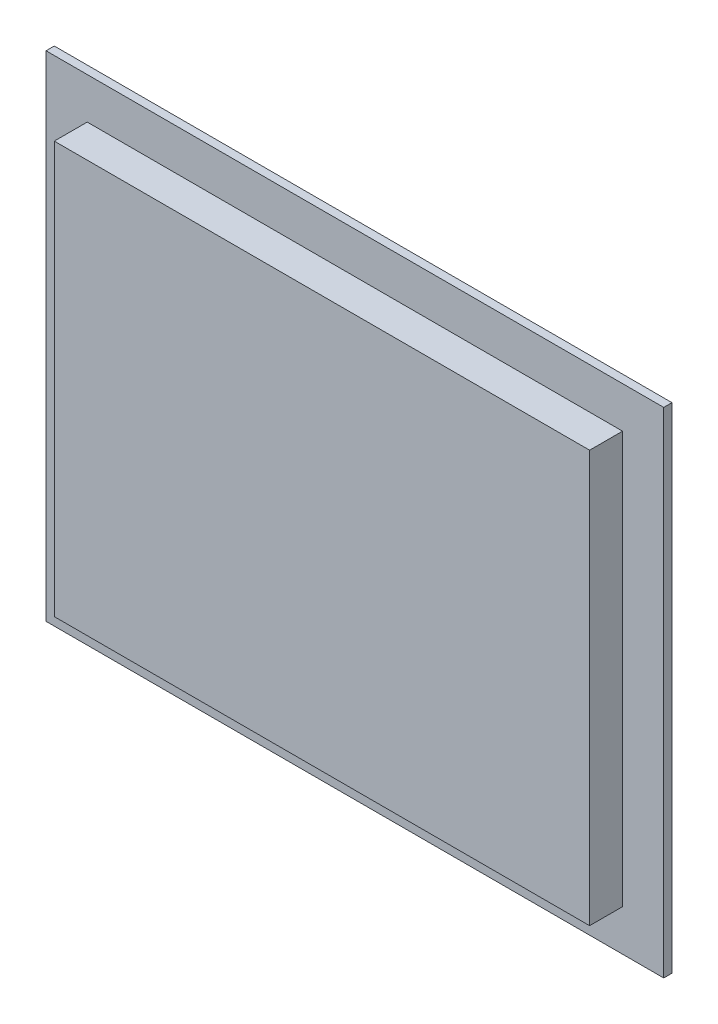
from build123d import *

# Parameters (mm, degrees)
SKETCH1_W                = 300
SKETCH1_H                = 240
SKETCH1_W_2              = 260
SKETCH1_H_2              = 200
BOSS_EXTRUDE1_DEPTH      = 4
SKETCH2_W                = 260
SKETCH2_H                = 200
SKETCH2_W_2              = 252.2
SKETCH2_H_2              = 194
BOSS_EXTRUDE3_DEPTH      = 16
BOSS_EXTRUDE3_DEPTH_BACK = 4
SKETCH4_W                = 252.2
SKETCH4_H                = 194
BOSS_EXTRUDE4_DEPTH      = 4


with BuildPart() as part:
    # Sketch1 → Boss-Extrude1 (new body)
    with BuildSketch(Plane.XY):
        Rectangle(SKETCH1_W, SKETCH1_H)
        Rectangle(SKETCH1_W_2, SKETCH1_H_2, mode=Mode.SUBTRACT)
    extrude(amount=BOSS_EXTRUDE1_DEPTH)

    # Sketch2 → Boss-Extrude3 (add, two sides)
    with BuildSketch(Plane.XY.offset(4)) as boss_extrude3_sk:
        Rectangle(SKETCH2_W, SKETCH2_H)
        Rectangle(SKETCH2_W_2, SKETCH2_H_2, mode=Mode.SUBTRACT)
    extrude(amount=BOSS_EXTRUDE3_DEPTH)
    extrude(boss_extrude3_sk.sketch, amount=-BOSS_EXTRUDE3_DEPTH_BACK)

    # Sketch4 → Boss-Extrude4 (add)
    with BuildSketch(Plane.XY.offset(20)):
        Rectangle(SKETCH4_W, SKETCH4_H)
    extrude(amount=-BOSS_EXTRUDE4_DEPTH)


solid = part.part
